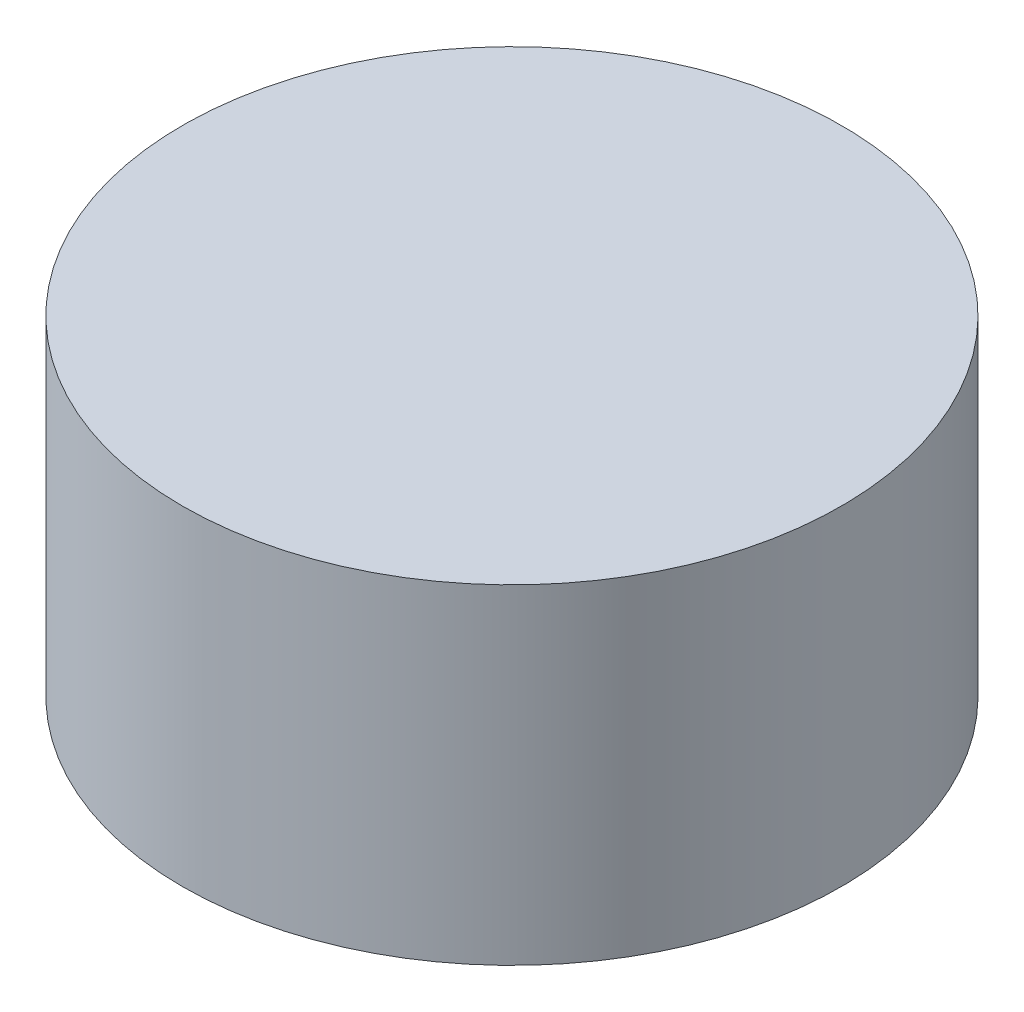
from build123d import *

# Parameters (mm, degrees)
SKETCH_1_R      = 6
SKETCH_1_R_2    = 3
EXTRUDE_1_DEPTH = 3
SKETCH_3_R      = 6
EXTRUDE_2_DEPTH = 3


with BuildPart() as part:
    # 스케치1 → 보스-돌출1 (new body)
    with BuildSketch(Plane(origin=(0, 0, 0), x_dir=(1, 0, 0), z_dir=(0, 1, 0))):
        Circle(SKETCH_1_R)
        Circle(SKETCH_1_R_2, mode=Mode.SUBTRACT)
    extrude(amount=EXTRUDE_1_DEPTH)

    # 스케치3 → 보스-돌출2 (add)
    with BuildSketch(Plane(origin=(0, 3, 0), x_dir=(1, 0, 0), z_dir=(0, 1, 0))):
        Circle(SKETCH_3_R)
    extrude(amount=EXTRUDE_2_DEPTH)


solid = part.part
